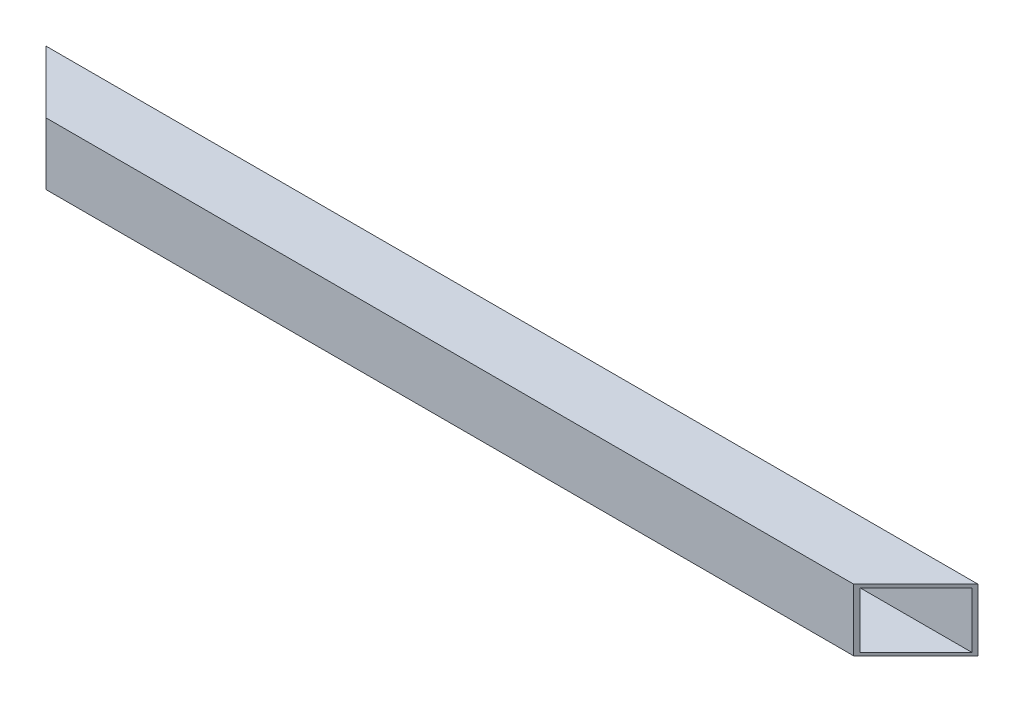
from build123d import *

# Parameters (mm, degrees)
CROQUIS1_W              = 40
CROQUIS1_H              = 40
CROQUIS1_W_2            = 36
CROQUIS1_H_2            = 36
SALIENTE_EXTRUIR1_DEPTH = 600
CORTAR_EXTRUIR2_DEPTH   = 41


with BuildPart() as part:
    # Croquis1 → Saliente-Extruir1 (new body)
    with BuildSketch(Plane(origin=(0, 0, 0), x_dir=(0, 0, -1), z_dir=(1, 0, 0))):
        Rectangle(CROQUIS1_W, CROQUIS1_H)
        Rectangle(CROQUIS1_W_2, CROQUIS1_H_2, mode=Mode.SUBTRACT)
    extrude(amount=SALIENTE_EXTRUIR1_DEPTH)

    # Croquis2 → Cortar-Extruir2 (cut, through all)
    with BuildSketch(Plane(origin=(0, 20, 0), x_dir=(1, 0, 0), z_dir=(0, 1, 0))):
        Polygon((0, 20), (0, -20), (40, -20), align=None)
        Polygon((560, -20), (600, 20), (600, -20), align=None)
    extrude(amount=-CORTAR_EXTRUIR2_DEPTH, mode=Mode.SUBTRACT)


solid = part.part
